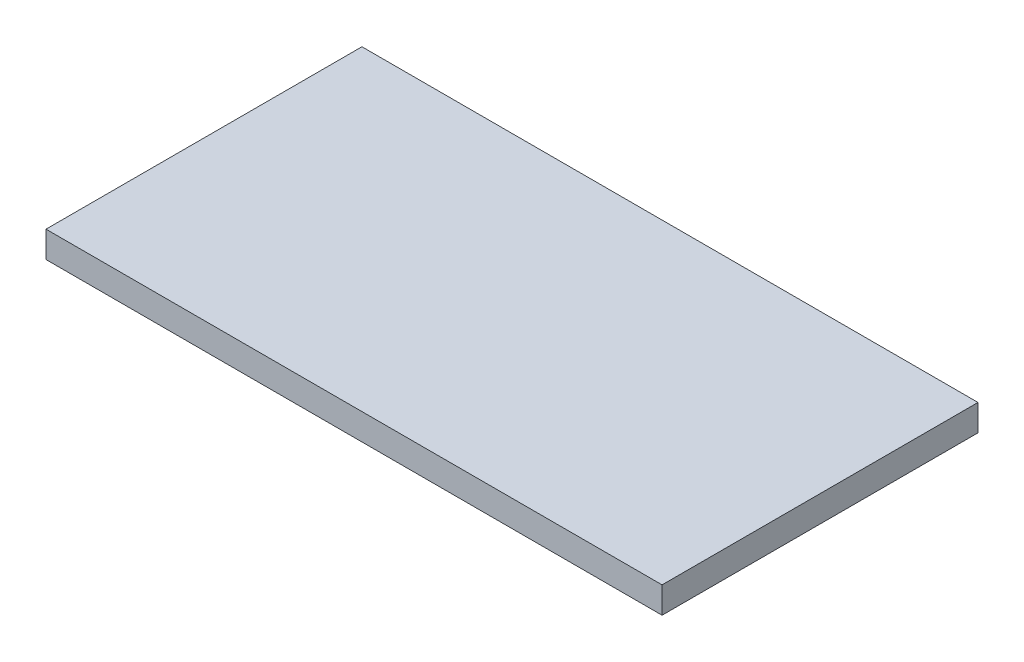
from build123d import *

# Parameters (mm, degrees)
SKETCH1_W           = 117
SKETCH1_H           = 60
BOSS_EXTRUDE1_DEPTH = 5


with BuildPart() as part:
    # Sketch1 → Boss-Extrude1 (new body)
    with BuildSketch(Plane(origin=(0, 0, 0), x_dir=(1, 0, 0), z_dir=(0, 1, 0))):
        Rectangle(SKETCH1_W, SKETCH1_H)
    extrude(amount=BOSS_EXTRUDE1_DEPTH)


solid = part.part
